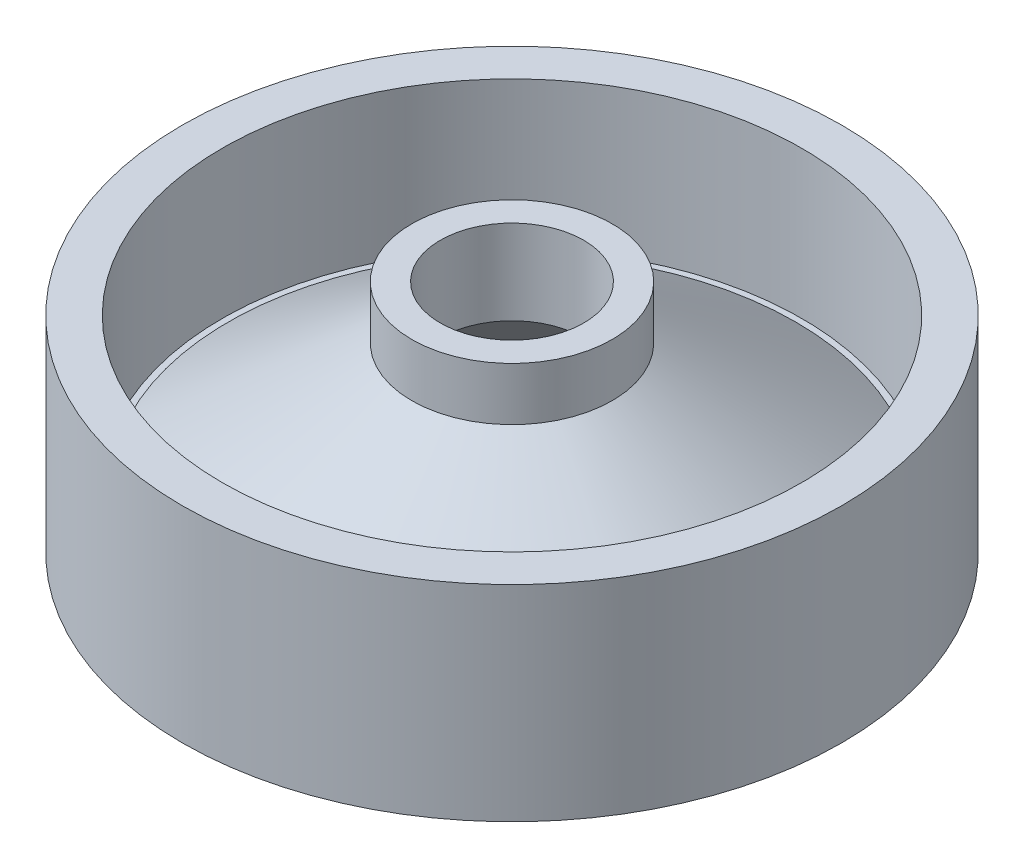
from build123d import *

# Parameters (mm, degrees)
SKETCH_1_R          = 11.38
EXTRUDE_1_DEPTH     = 7.09
SKETCH_2_R          = 10
CUT_EXTRUDE_1_DEPTH = 5.09
SKETCH_3_R          = 3.46
EXTRUDE_2_DEPTH     = 6.1
SKETCH_4_R          = 3.46
EXTRUDE_3_DEPTH     = 5.18
EXTRUDE_3_DRAFT     = 56
SKETCH_5_R          = 8.873129811
CUT_EXTRUDE_2_DEPTH = 5.18
CUT_EXTRUDE_2_DRAFT = -51
SKETCH_6_R          = 2.476362541
CUT_EXTRUDE_3_DEPTH = 3.92


with BuildPart() as part:
    # 草图1 → 凸台-拉伸1 (new body)
    with BuildSketch(Plane(origin=(0, 0, 0), x_dir=(1, 0, 0), z_dir=(0, 1, 0))):
        with Locations(Location((0, 0, 0), (0, 0, 270))):  # turned: the seam where the file's is
            Circle(SKETCH_1_R)
    extrude(amount=EXTRUDE_1_DEPTH)

    # 草图2 → 切除-拉伸1 (cut)
    with BuildSketch(Plane(origin=(0, 7.09, 0), x_dir=(1, 0, 0), z_dir=(0, 1, 0))):
        with Locations(Location((0, 0, 0), (0, 0, 270))):  # turned: the seam where the file's is
            Circle(SKETCH_2_R)
    extrude(amount=-CUT_EXTRUDE_1_DEPTH, mode=Mode.SUBTRACT)

    # 草图3 → 凸台-拉伸2 (add)
    with BuildSketch(Plane(origin=(0, 2, 0), x_dir=(1, 0, 0), z_dir=(0, 1, 0))):
        with Locations(Location((0, 0, 0), (0, 0, 270))):  # turned: the seam where the file's is
            Circle(SKETCH_3_R)
    extrude(amount=EXTRUDE_2_DEPTH)


with BuildPart() as extrude_3_tool:
    # 草图4 → 凸台-拉伸3 (with draft: the straight prism first)
    with BuildSketch(Plane(origin=(0, 6.27, 0), x_dir=(1, 0, 0), z_dir=(0, 1, 0))):
        with Locations(Location((0, 0, 0), (0, 0, 270))):  # turned: the seam where the file's is
            Circle(SKETCH_4_R)
    extrude(amount=-EXTRUDE_3_DEPTH)
    # 凸台-拉伸3: the draft: its side faces are tilted about the plane it starts from
    extrude_3_sides = [extrude_3_tool.faces().sort_by_distance(p)[0] for p in [
        (0, 3.68, -3.46),
    ]]
    draft(extrude_3_sides, Plane(origin=(0, 6.27, 0), x_dir=(1, 0, 0), z_dir=(0, 1, 0)), EXTRUDE_3_DRAFT)


with BuildPart() as part_1:
    add(part.part)

    # 凸台-拉伸3: add extrude_3_tool
    add(extrude_3_tool.part)


with BuildPart() as cut_extrude_2_tool:
    # 草图5 → 切除-拉伸2 (with draft: the straight prism first)
    with BuildSketch(Plane.XZ):
        Circle(SKETCH_5_R)
    extrude(amount=-CUT_EXTRUDE_2_DEPTH)
    # 切除-拉伸2: the draft: its side faces are tilted about the plane it starts from
    cut_extrude_2_sides = [cut_extrude_2_tool.faces().sort_by_distance(p)[0] for p in [
        (-8.873129811, 2.59, 0),
    ]]
    draft(cut_extrude_2_sides, Plane.XZ, CUT_EXTRUDE_2_DRAFT)


with BuildPart() as part_2:
    add(part_1.part)

    # 切除-拉伸2: cut by cut_extrude_2_tool
    add(cut_extrude_2_tool.part, mode=Mode.SUBTRACT)

    # 草图6 → 切除-拉伸3 (cut, through all)
    with BuildSketch(Plane.XZ.offset(-5.18)):
        with Locations(Location((0, 0, 0), (0, 0, 270))):  # turned: the seam where the file's is
            Circle(SKETCH_6_R)
    extrude(amount=-CUT_EXTRUDE_3_DEPTH, mode=Mode.SUBTRACT)


solid = part_2.part
